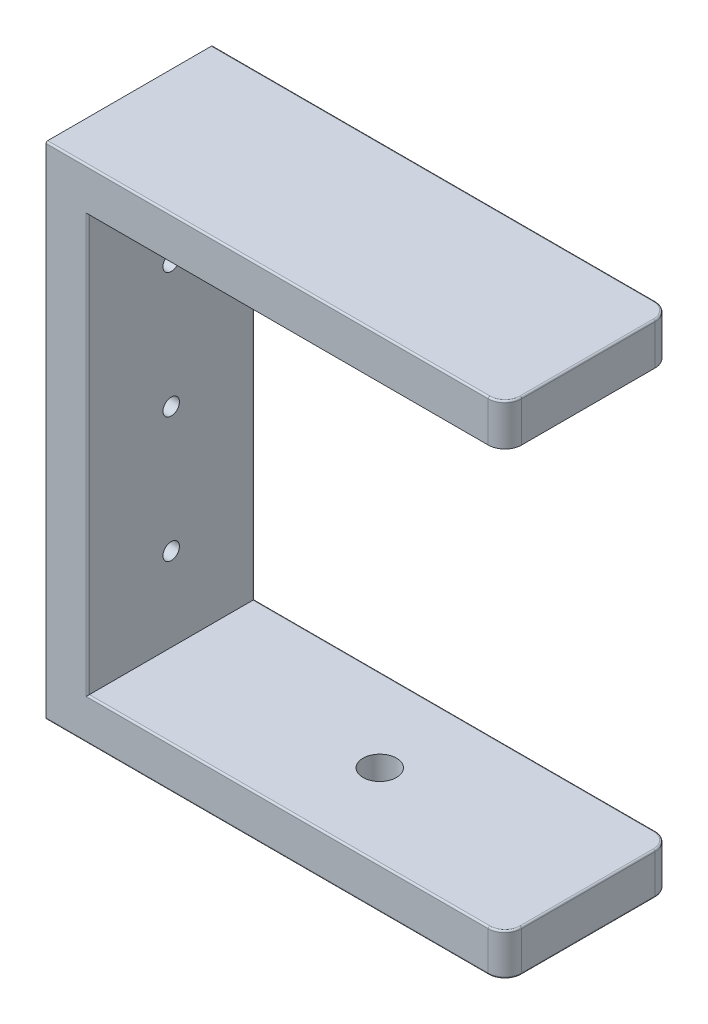
from build123d import *

# Parameters (mm, degrees)
BOSS_EXTRUDE1_DEPTH         = 25.4
M3X0_5_TAPPED_HOLE1_D       = 2.5
F_1_4_20_TAPPED_HOLE1_D     = 5.1054
F_1_4_20_TAPPED_HOLE1_DEPTH = 6.35
FILLET1_R                   = 2.54
FILLET2_R                   = 0.254


with BuildPart() as part:
    # Sketch1 → Boss-Extrude1 (new body)
    with BuildSketch(Plane.XY):
        Polygon((69.85, 69.85), (69.85, 76.2), (0, 76.2), (0, 0), (69.85, 0), (69.85, 6.35), (6.35, 6.35), (6.35, 69.85), align=None)
    extrude(amount=BOSS_EXTRUDE1_DEPTH)

    # M3x0.5 Tapped Hole1 (through all)
    with Locations(Plane.ZY):
        with Locations((12.7, 57.15), (12.7, 38.1), (12.7, 19.05)):
            Hole(M3X0_5_TAPPED_HOLE1_D / 2)

    # 1/4-20 Tapped Hole1
    with Locations(Plane(origin=(0, 0, 0), x_dir=(-1, 0, 0), z_dir=(0, -1, 0))):
        with Locations((-38.1, -12.7)):
            Hole(F_1_4_20_TAPPED_HOLE1_D / 2, depth=F_1_4_20_TAPPED_HOLE1_DEPTH)

    # Fillet1
    fillet1_edges = [part.edges().sort_by_distance(p)[0] for p in [
        (69.85, 3.175, 0),
        (69.85, 3.175, 25.4),
        (69.85, 73.025, 25.4),
        (69.85, 73.025, 0),
    ]]
    fillet(fillet1_edges, radius=FILLET1_R)

    # Fillet2
    fillet2_edges = [part.edges().sort_by_distance(p)[0] for p in [
        (33.655, 0, 0),
        (6.35, 38.1, 25.4),
        (69.85, 6.35, 12.7),
        (69.85, 0, 12.7),
        (36.83, 6.35, 0),
        (36.83, 6.35, 25.4),
        (69.106051224, 6.35, 24.656051224),
        (69.106051224, 6.35, 0.743948776),
        (33.655, 76.2, 0),
        (69.106051224, 0, 24.656051224),
        (69.106051224, 0, 0.743948776),
        (33.655, 76.2, 25.4),
        (69.85, 76.2, 12.7),
        (69.106051224, 76.2, 24.656051224),
        (69.106051224, 76.2, 0.743948776),
        (33.655, 0, 25.4),
        (6.35, 38.1, 0),
    ]]
    fillet(fillet2_edges, radius=FILLET2_R)


solid = part.part
